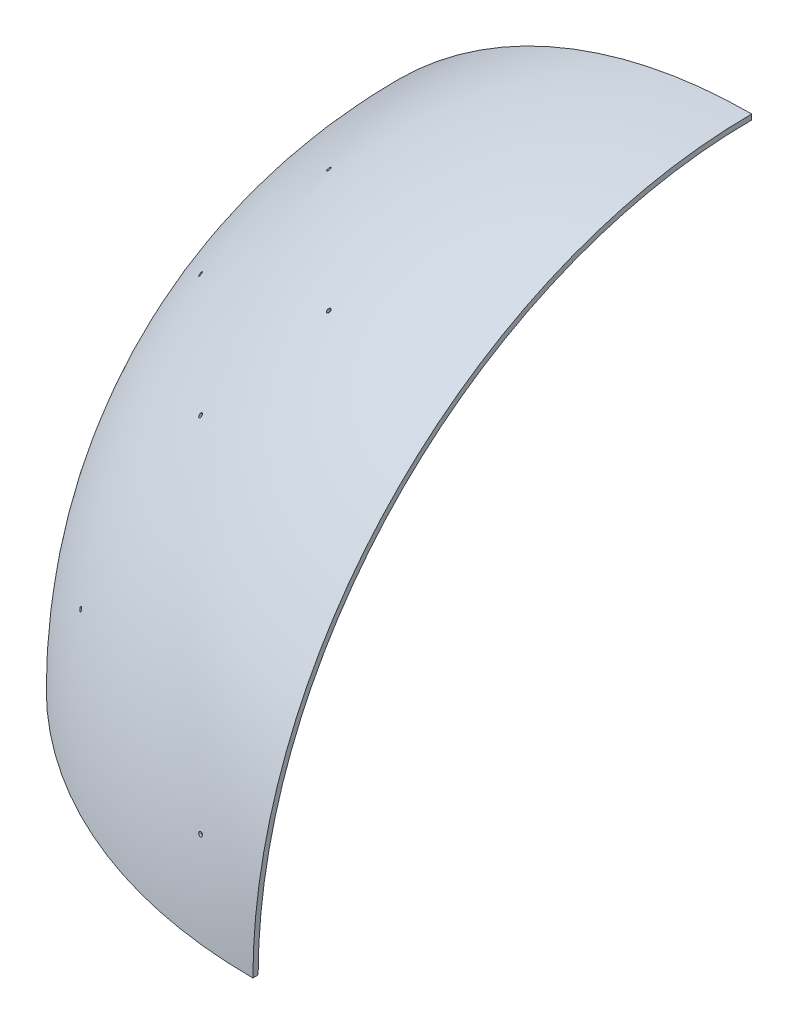
from build123d import *

# Parameters (mm, degrees)
REVOLVE1_ANGLE    = 90
CIRPATTERN3_COUNT = 2
CIRPATTERN3_ANGLE = 120


with BuildPart() as part:
    # Sketch1 → Revolve1 (revolve)
    with BuildSketch(Plane.XY):
        with BuildLine():
            ThreePointArc((-235, 0), (-166.170093579, 166.170093579), (0, 235))
            Line((0, 235), (0, 237.5))
            ThreePointArc((0, 237.5), (-167.937860532, 167.937860532), (-237.5, 0))
            Line((-237.5, 0), (-235, 0))
        make_face()
    revolve(axis=Axis((0, 0, 0), (0, 1, 0)), revolution_arc=REVOLVE1_ANGLE)

    # Sketch3 → Cut-Revolve1 (revolve, cut)
    with BuildSketch(Plane(origin=(0, 0, 0), x_dir=(0, 1, 0), z_dir=(0.9914448613738104, 0, 0.13052619222005188))):
        with BuildLine():
            ThreePointArc((40.807321752, 231.429821958), (42.283732139, 231.16462964), (43.758419697, 230.890018636))
            Line((43.758419697, 230.890018636), (43.975497515, 232.121128117))
            ThreePointArc((43.975497515, 232.121128117), (42.992545036, 232.305194887), (42.008822216, 232.485099213))
            Line((42.008822216, 232.485099213), (42.225884372, 233.716119874))
            ThreePointArc((42.225884372, 233.716119874), (41.733755769, 233.804498736), (41.241442196, 233.89184134))
            Line((41.241442196, 233.89184134), (40.807321752, 231.429821958))
        make_face()
    cut_revolve1 = revolve(axis=Axis((0, 0, 0), (-0.12854320606946884, 0.17364817766693075, 0.9763825861650424)), mode=Mode.SUBTRACT)

    # Mirror2: Cut-Revolve1 across plane
    add(cut_revolve1.mirror(Plane(origin=(0, 0, 0), x_dir=(-0.28867513459481386, 0.4082482904638622, 0.8660254037844386), z_dir=(-0.5000000000000019, 0.7071067811865464, -0.4999999999999999))), mode=Mode.SUBTRACT)

    # CirPattern3: Cut-Revolve1 ×2 about axis
    cirpattern3_axis = Axis((0, -50, -70.710678119), (0, -0.5773502691896264, -0.8164965809277257))
    for i in range(1, CIRPATTERN3_COUNT):
        add(cut_revolve1.rotate(cirpattern3_axis, i * CIRPATTERN3_ANGLE / (CIRPATTERN3_COUNT - 1)), mode=Mode.SUBTRACT)

    # Mirror5: Cut-Revolve1 across plane
    add(cut_revolve1.mirror(Plane(origin=(0, 0, 0), x_dir=(-0.7071067811865489, 0, 0.7071067811865462), z_dir=(0.7071067811865464, 0, 0.7071067811865488))), mode=Mode.SUBTRACT)

    # Mirror5 copy 1 sketch → Mirror5 copy 1 (revolve, cut)
    with BuildSketch(Plane(origin=(0, 0, 0), x_dir=(-0.707106781186544, 3.3306690738754696e-15, -0.7071067811865517), z_dir=(0.43045933457688246, 0.7933533402912366, -0.43045933457687385))):
        with BuildLine():
            ThreePointArc((40.807321752, 231.429821958), (42.283732139, 231.16462964), (43.758419697, 230.890018636))
            Line((43.758419697, 230.890018636), (43.975497515, 232.121128117))
            ThreePointArc((43.975497515, 232.121128117), (42.992545036, 232.305194887), (42.008822216, 232.485099213))
            Line((42.008822216, 232.485099213), (42.225884372, 233.716119874))
            ThreePointArc((42.225884372, 233.716119874), (41.733755769, 233.804498736), (41.241442196, 233.89184134))
            Line((41.241442196, 233.89184134), (40.807321752, 231.429821958))
        make_face()
    revolve(axis=Axis((0, 0, 0), (-0.6752507000862306, 0.5995129750225779, 0.42967509214828115)), mode=Mode.SUBTRACT)

    # Mirror5 copy 2 sketch → Mirror5 copy 2 (revolve, cut)
    with BuildSketch(Plane(origin=(0, 0, 0), x_dir=(-0.7071067811865479, -1.887379141862766e-15, -0.7071067811865478), z_dir=(-0.5609855267969319, -0.6087614290087177, 0.5609855267969336))):
        with BuildLine():
            ThreePointArc((40.807321752, -231.429821958), (42.283732139, -231.16462964), (43.758419697, -230.890018636))
            Line((43.758419697, -230.890018636), (43.975497515, -232.121128117))
            ThreePointArc((43.975497515, -232.121128117), (42.992545036, -232.305194887), (42.008822216, -232.485099213))
            Line((42.008822216, -232.485099213), (42.225884372, -233.716119874))
            ThreePointArc((42.225884372, -233.716119874), (41.733755769, -233.804498736), (41.241442196, -233.89184134))
            Line((41.241442196, -233.89184134), (40.807321752, -231.429821958))
        make_face()
    revolve(axis=Axis((0, 0, 0), (0.5467074940167592, -0.7813005203969431, -0.3011318860788107)), mode=Mode.SUBTRACT)

    # Sketch7 → Cut-Revolve2 (revolve, cut)
    with BuildSketch(Plane(origin=(0, 0, 0), x_dir=(0, 1, 0), z_dir=(0.819152044288991, 0, 0.5735764363510473))):
        with BuildLine():
            ThreePointArc((60.822475599, 226.992569178), (62.270154766, 226.599708353), (63.715296767, 226.197614837))
            Line((63.715296767, 226.197614837), (64.038846799, 227.405119997))
            ThreePointArc((64.038846799, 227.405119997), (63.075677226, 227.67415629), (62.111377464, 227.939113119))
            Line((62.111377464, 227.939113119), (62.434904154, 229.146531161))
            ThreePointArc((62.434904154, 229.146531161), (61.952350974, 229.277465549), (61.469523212, 229.407383744))
            Line((61.469523212, 229.407383744), (60.822475599, 226.992569178))
        make_face()
    cut_revolve2 = revolve(axis=Axis((0, 0, 0), (-0.5540322932223244, 0.25881904510252146, 0.791240115236223)), mode=Mode.SUBTRACT)

    # Mirror6: Cut-Revolve2 across plane
    add(cut_revolve2.mirror(Plane(origin=(0, 0, 0), x_dir=(-0.7071067811865489, 0, 0.7071067811865462), z_dir=(0.7071067811865464, 0, 0.7071067811865488))), mode=Mode.SUBTRACT)


solid = part.part
